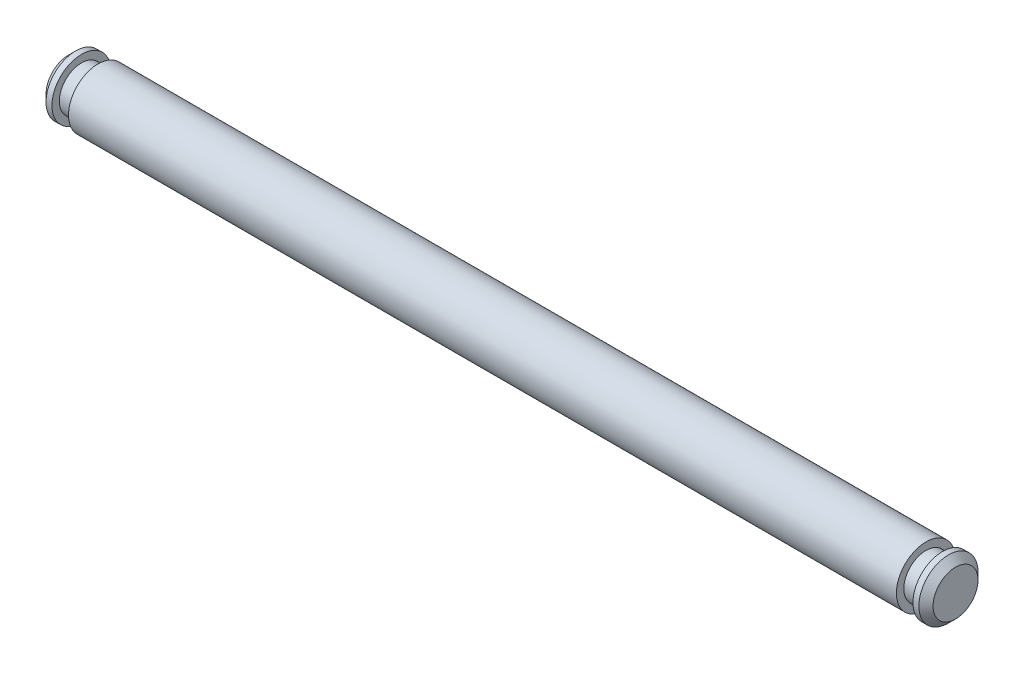
from build123d import *


with BuildPart() as part:
    # Sketch1 → Revolve1 (revolve)
    with BuildSketch(Plane.XY):
        Polygon((0, 0), (95.25, 0), (95.25, 2.413), (94.488, 3.175), (93.853, 3.175), (93.853, 2.38125), (92.075, 2.38125), (92.075, 3.175), (3.175, 3.175), (3.175, 2.38125), (1.397, 2.38125), (1.397, 3.175), (0.762, 3.175), (0, 2.413), align=None)
    revolve(axis=Axis((0, 0, 0), (-1, 0, 0)))


solid = part.part
